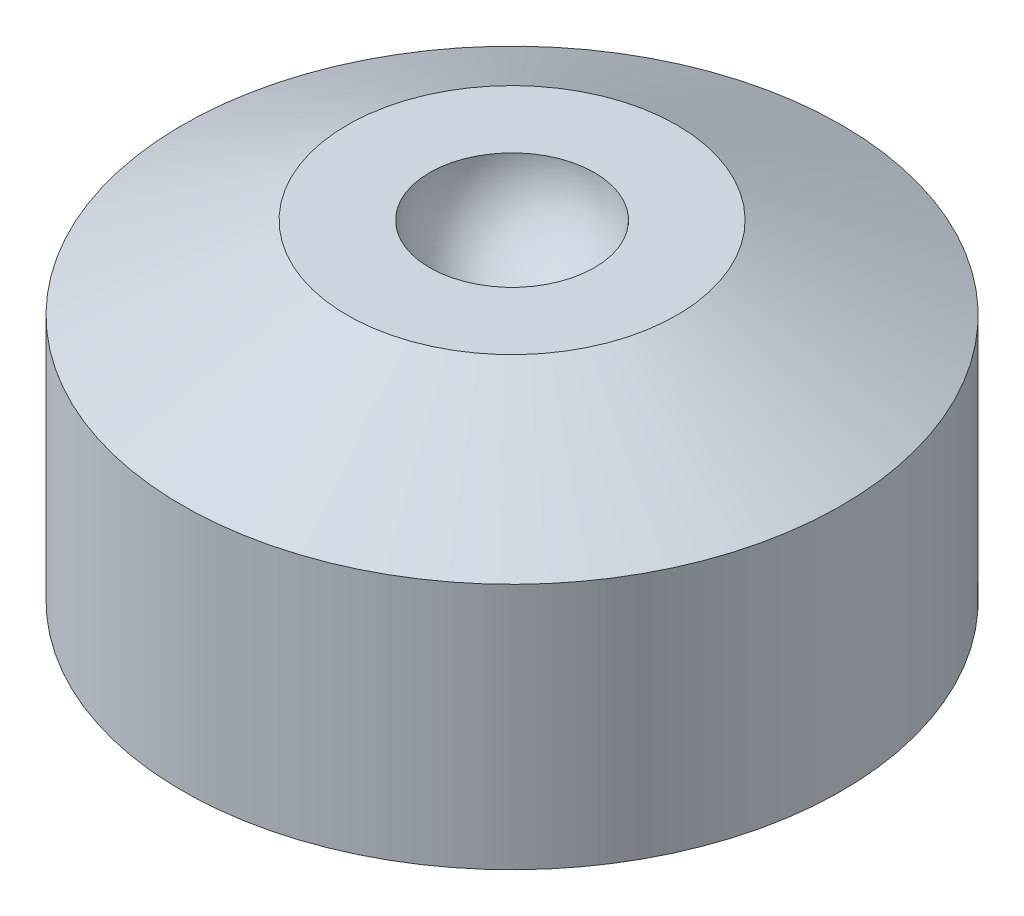
from build123d import *


with BuildPart() as part:
    # Sketch1 → Revolve1 (revolve)
    with BuildSketch(Plane(origin=(0, 0, 0), x_dir=(0, 0, -1), z_dir=(1, 0, 0))):
        with BuildLine():
            Line((0, 0), (-25.4, 0))
            Line((-25.4, 0), (-25.4, 19.05))
            Line((-25.4, 19.05), (-12.7, 25.4))
            Line((-12.7, 25.4), (-6.35, 25.4))
            ThreePointArc((-6.35, 25.4), (-4.490128061, 20.909871939), (0, 19.05))
            Line((0, 19.05), (0, 9.548847794))
            Line((0, 9.548847794), (0, 0))
        make_face()
    revolve(axis=Axis((0, 0, 0), (0, 1, 0)))


solid = part.part
